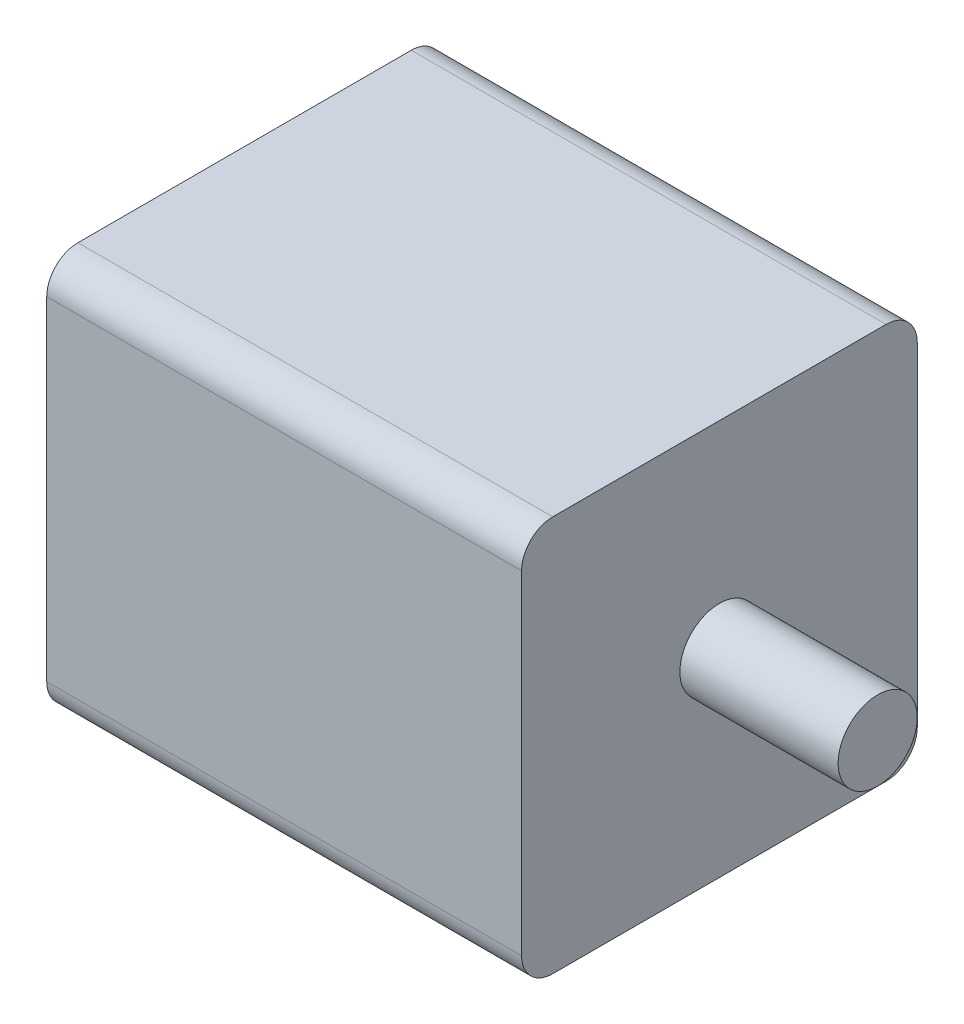
from build123d import *

# Parameters (mm, degrees)
BOSS_EXTRUDE1_DEPTH = 76.2
SKETCH2_R           = 12.7
BOSS_EXTRUDE2_DEPTH = 50.8


with BuildPart() as part:
    # Sketch1 → Boss-Extrude1 (new body, symmetric)
    with BuildSketch(Plane(origin=(0, 0, 0), x_dir=(0, 0, -1), z_dir=(1, 0, 0))):
        with BuildLine():
            Line((-53.5, 63.5), (53.5, 63.5))
            ThreePointArc((53.5, 63.5), (60.571067812, 60.571067812), (63.5, 53.5))
            Line((63.5, 53.5), (63.5, -53.5))
            ThreePointArc((63.5, -53.5), (60.571067812, -60.571067812), (53.5, -63.5))
            Line((53.5, -63.5), (-53.5, -63.5))
            ThreePointArc((-53.5, -63.5), (-60.571067812, -60.571067812), (-63.5, -53.5))
            Line((-63.5, -53.5), (-63.5, 53.5))
            ThreePointArc((-63.5, 53.5), (-60.571067812, 60.571067812), (-53.5, 63.5))
        make_face()
    extrude(amount=BOSS_EXTRUDE1_DEPTH, both=True)

    # Sketch2 → Boss-Extrude2 (add)
    with BuildSketch(Plane(origin=(76.2, 0, 0), x_dir=(0, 0, -1), z_dir=(1, 0, 0))):
        Circle(SKETCH2_R)
    extrude(amount=BOSS_EXTRUDE2_DEPTH)


solid = part.part
